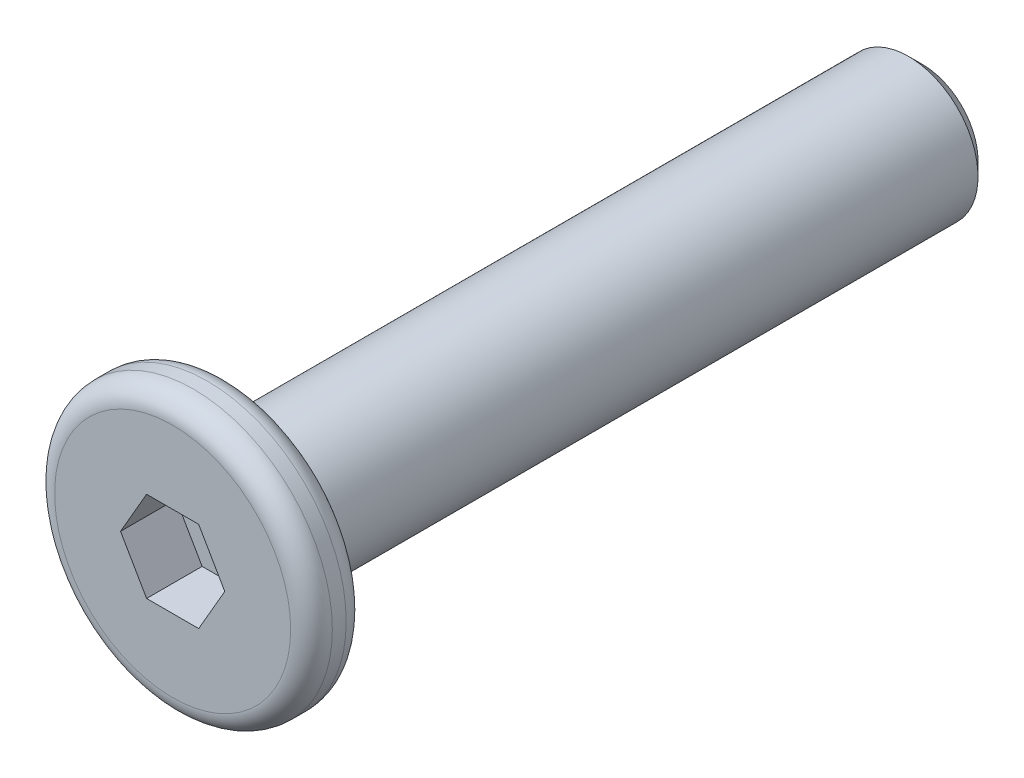
from build123d import *

# Parameters (mm, degrees)
SKETCH_1_R          = 2
EXTRUDE_1_DEPTH     = 0.4
SKETCH_2_R          = 1
EXTRUDE_2_DEPTH     = 10
CHAMFER_1_SIZE      = 0.2
CUT_EXTRUDE_1_DEPTH = 0.8
FILLET_2_R          = 0.3


with BuildPart() as part:
    # 草图1 → 凸台-拉伸1 (new body, symmetric)
    with BuildSketch(Plane.XY):
        Circle(SKETCH_1_R)
    extrude(amount=EXTRUDE_1_DEPTH, both=True)

    # 草图2 → 凸台-拉伸2 (add)
    with BuildSketch(Plane(origin=(0, 0, -0.4), x_dir=(-1, 0, 0), z_dir=(0, 0, -1))):
        Circle(SKETCH_2_R)
    extrude(amount=EXTRUDE_2_DEPTH)

    # 倒角1
    chamfer_1_edges = [part.edges().sort_by_distance(p)[0] for p in [
        (1, 0, -10.4),
    ]]
    chamfer(chamfer_1_edges, length=CHAMFER_1_SIZE)

    # 草图3 → 切除-拉伸1 (cut)
    with BuildSketch(Plane.XY.offset(0.4)):
        Polygon((0.75055535, 0), (0.375277675, 0.65), (-0.375277675, 0.65), (-0.75055535, 0), (-0.375277675, -0.65), (0.375277675, -0.65), align=None)
    extrude(amount=-CUT_EXTRUDE_1_DEPTH, mode=Mode.SUBTRACT)

    # 圆角2
    fillet_2_edges = [part.edges().sort_by_distance(p)[0] for p in [
        (-2, 0, -0.4),
        (-2, 0, 0.4),
    ]]
    fillet(fillet_2_edges, radius=FILLET_2_R)


solid = part.part
